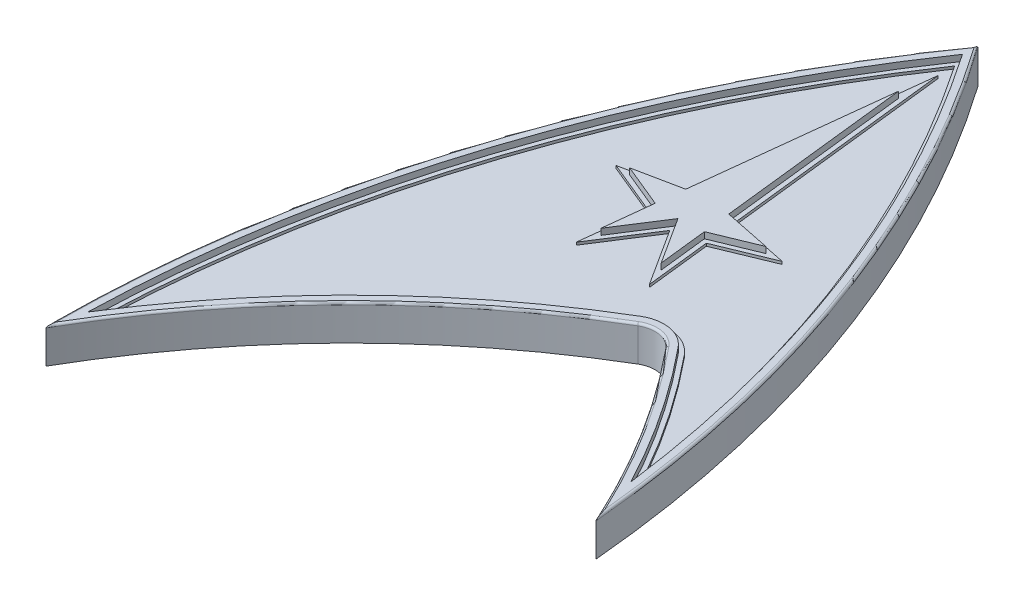
from build123d import *

# Parameters (mm, degrees)
BOSS_EXTRUDE4_START  = 2.3
BOSS_EXTRUDE4_DEPTH  = 0.7
BOSS_EXTRUDE5_DEPTH  = 3.3
BOSS_EXTRUDE6_DEPTH  = 3.3
BOSS_EXTRUDE7_DEPTH  = 4
BOSS_EXTRUDE8_DEPTH  = 4
BOSS_EXTRUDE11_DEPTH = 0.4
FILLET1_R            = 1
BOSS_EXTRUDE13_DEPTH = 0.4
FILLET2_R            = 0.25


with BuildPart() as part:
    # Sketch7 → Boss-Extrude4 (new body)
    with BuildSketch(Plane(origin=(0, 0, 0), x_dir=(1, 0, 0), z_dir=(0, 1, 0)).offset(BOSS_EXTRUDE4_START)):
        with BuildLine():
            ThreePointArc((25.3187138, 78.544271563), (7.774655726, 42.865584467), (1.048717339, 3.67981614))
            ThreePointArc((1.048717339, 3.67981614), (15.089584113, 21.033250642), (32.814888894, 34.601640347))
            ThreePointArc((32.814888894, 34.601640347), (35.548345535, 35.099201296), (37.946501588, 33.696275907))
            ThreePointArc((37.946501588, 33.696275907), (43.624222728, 26.008293603), (48.494904785, 17.785274356))
            ThreePointArc((48.494904785, 17.785274356), (40.509944663, 49.539169466), (25.3187138, 78.544271563))
        make_face()
        Polygon((25.3187138, 71.300701089), (22.880167391, 49.619221751), (17.607947401, 48.538636703), (22.53025342, 46.508084516), (21.9096513, 40.990218623), (25.3187138, 46.300701089), (28.7277763, 40.990218623), (28.107174179, 46.508084516), (33.029480199, 48.538636703), (27.757260208, 49.619221751), align=None, mode=Mode.SUBTRACT)
    extrude(amount=BOSS_EXTRUDE4_DEPTH)


with BuildPart() as body_2:
    # Sketch11 → Boss-Extrude5 (new body)
    with BuildSketch(Plane(origin=(0, 0, 0), x_dir=(1, 0, 0), z_dir=(0, 1, 0))):
        Polygon((25.3187138, 75.774305051), (22.423901789, 50.036100284), (15.905432755, 48.700086198), (21.991275042, 46.189551437), (21.173408654, 38.917779558), (25.3187138, 45.375147323), (29.464018945, 38.917779558), (28.646152557, 46.189551437), (34.731994844, 48.700086198), (28.21352581, 50.036100284), align=None)
    extrude(amount=BOSS_EXTRUDE5_DEPTH)

    # Sketch4 → Boss-Extrude8 (add)
    with BuildSketch(Plane(origin=(0, 0, 0), x_dir=(1, 0, 0), z_dir=(0, 1, 0))):
        Polygon((25.3187138, 71.300701089), (22.880167391, 49.619221751), (17.607947401, 48.538636703), (22.53025342, 46.508084516), (21.9096513, 40.990218623), (25.3187138, 46.300701089), (28.7277763, 40.990218623), (28.107174179, 46.508084516), (33.029480199, 48.538636703), (27.757260208, 49.619221751), align=None)
    extrude(amount=BOSS_EXTRUDE8_DEPTH)



with BuildPart() as body_3:
    # Sketch8 → Boss-Extrude6 (new body)
    with BuildSketch(Plane(origin=(0, 0, 0), x_dir=(1, 0, 0), z_dir=(0, 1, 0))):
        with BuildLine():
            ThreePointArc((25.3187138, 80.300701089), (6.479626895, 42.098811931), (0, 0))
            ThreePointArc((0, 0), (14.483479935, 19.022484189), (33.324507598, 33.741239989))
            ThreePointArc((33.324507598, 33.741239989), (35.374600079, 34.114410701), (37.173217119, 33.062216659))
            ThreePointArc((37.173217119, 33.062216659), (44.32763613, 23.058929343), (50.104685332, 12.201803985))
            ThreePointArc((50.104685332, 12.201803985), (42.194394509, 47.882820066), (25.3187138, 80.300701089))
        make_face()
        with BuildLine():
            ThreePointArc((25.3187138, 77.655988793), (8.417285199, 43.223132296), (1.60825988, 5.475058578))
            ThreePointArc((1.60825988, 5.475058578), (15.395050063, 22.022293224), (32.560079542, 35.031840527))
            ThreePointArc((32.560079542, 35.031840527), (35.635218263, 35.591596594), (38.333143822, 34.01330553))
            ThreePointArc((38.333143822, 34.01330553), (43.27239761, 27.425793547), (47.621637666, 20.434681115))
            ThreePointArc((47.621637666, 20.434681115), (39.681799875, 50.297117055), (25.3187138, 77.655988793))
        make_face(mode=Mode.SUBTRACT)
    extrude(amount=BOSS_EXTRUDE6_DEPTH)

    # Sketch5 → Boss-Extrude7 (add)
    with BuildSketch(Plane(origin=(0, 0, 0), x_dir=(1, 0, 0), z_dir=(0, 1, 0))):
        with BuildLine():
            ThreePointArc((33.324507598, 33.741239989), (14.483479935, 19.022484189), (0, 0))
            ThreePointArc((0, 0), (6.479626895, 42.098811931), (25.3187138, 80.300701089))
            ThreePointArc((25.3187138, 80.300701089), (42.194394509, 47.882820066), (50.104685332, 12.201803985))
            ThreePointArc((50.104685332, 12.201803985), (44.32763613, 23.058929343), (37.173217119, 33.062216659))
            ThreePointArc((37.173217119, 33.062216659), (35.374600079, 34.114410701), (33.324507598, 33.741239989))
        make_face()
        with BuildLine():
            ThreePointArc((48.494904785, 17.785274356), (43.624222728, 26.008293603), (37.946501588, 33.696275907))
            ThreePointArc((37.946501588, 33.696275907), (35.548345535, 35.099201296), (32.814888894, 34.601640347))
            ThreePointArc((32.814888894, 34.601640347), (15.089584113, 21.033250642), (1.048717339, 3.67981614))
            ThreePointArc((1.048717339, 3.67981614), (7.774655726, 42.865584467), (25.3187138, 78.544271563))
            ThreePointArc((25.3187138, 78.544271563), (40.509944663, 49.539169466), (48.494904785, 17.785274356))
        make_face(mode=Mode.SUBTRACT)
    extrude(amount=BOSS_EXTRUDE7_DEPTH)


with BuildPart() as body_2_1:
    add(body_2.part)

    add(body_3.part)  # Boss-Extrude11 merges body 3
    # Sketch14 → Boss-Extrude11 (add)
    with BuildSketch(Plane(origin=(0, 0, 0), x_dir=(1, 0, 0), z_dir=(0, 1, 0))):
        with BuildLine():
            ThreePointArc((33.324507598, 33.741239989), (14.483479935, 19.022484189), (0, 0))
            ThreePointArc((0, 0), (6.479626895, 42.098811931), (25.3187138, 80.300701089))
            ThreePointArc((25.3187138, 80.300701089), (42.194394509, 47.882820066), (50.104685332, 12.201803985))
            ThreePointArc((50.104685332, 12.201803985), (44.32763613, 23.058929343), (37.173217119, 33.062216659))
            ThreePointArc((37.173217119, 33.062216659), (35.374600079, 34.114410701), (33.324507598, 33.741239989))
        make_face()
        with BuildLine():
            Line((23.723630878, 70.539393135), (21.511370585, 50.869857351))
            Line((21.511370585, 50.869857351), (13.198167733, 49.16599774))
            ThreePointArc((13.198167733, 49.16599774), (17.991973603, 60.083620852), (23.723630878, 70.539393135))
        make_face(mode=Mode.SUBTRACT)
        with BuildLine():
            Line((13.054684669, 48.794332823), (20.913318286, 45.552485279))
            Line((20.913318286, 45.552485279), (19.700923362, 34.77290143))
            Line((19.700923362, 34.77290143), (25.3187138, 43.52403979))
            Line((25.3187138, 43.52403979), (29.919000612, 36.357922285))
            ThreePointArc((29.919000612, 36.357922285), (16.351293772, 26.297844628), (4.727035456, 14.043684112))
            ThreePointArc((4.727035456, 14.043684112), (7.744533302, 31.693714336), (13.054684669, 48.794332823))
        make_face(mode=Mode.SUBTRACT)
        with BuildLine():
            Line((30.704502872, 36.835660121), (29.724109313, 45.552485279))
            Line((29.724109313, 45.552485279), (37.58274293, 48.794332823))
            ThreePointArc((37.58274293, 48.794332823), (40.393915943, 40.733938341), (42.693859526, 32.513055637))
            ThreePointArc((42.693859526, 32.513055637), (41.495664758, 34.067994846), (40.266354995, 35.59845365))
            ThreePointArc((40.266354995, 35.59845365), (36.069581902, 38.053573082), (31.286032781, 37.182841422))
            ThreePointArc((31.286032781, 37.182841422), (30.994965848, 37.009756586), (30.704502872, 36.835660121))
        make_face(mode=Mode.SUBTRACT)
        with BuildLine():
            Line((37.439259866, 49.16599774), (29.126057014, 50.869857351))
            Line((29.126057014, 50.869857351), (26.913796721, 70.539393135))
            ThreePointArc((26.913796721, 70.539393135), (32.645453996, 60.083620852), (37.439259866, 49.16599774))
        make_face(mode=Mode.SUBTRACT)
    extrude(amount=BOSS_EXTRUDE11_DEPTH)

    # Fillet1
    fillet1_edges = [body_2_1.edges().sort_by_distance(p)[0] for p in [
        (29.919000612, 0.2, -36.357922285),
        (30.704502872, 0.2, -36.835660121),
        (37.439259866, 0.2, -49.16599774),
        (37.58274293, 0.2, -48.794332823),
        (13.054684669, 0.2, -48.794332823),
        (13.198167733, 0.2, -49.16599774),
    ]]
    fillet(fillet1_edges, radius=FILLET1_R)

    # Fillet2
    fillet2_edges = [body_2_1.edges().sort_by_distance(p)[0] for p in [
        (35.374600079, 4, -34.114410701),
        (44.32763613, 4, -23.058929343),
        (42.194394509, 4, -47.882820066),
        (6.479626895, 4, -42.098811931),
        (14.483479935, 4, -19.022484189),
    ]]
    fillet(fillet2_edges, radius=FILLET2_R)


with BuildPart() as body_3_2:
    # Sketch19 → Boss-Extrude13 (new body)
    with BuildSketch(Plane(origin=(0, 0.4, 0), x_dir=(1, 0, 0), z_dir=(0, 1, 0))):
        with BuildLine():
            Line((24.8466447, 76.050672339), (21.967636187, 50.452978818))
            Line((21.967636187, 50.452978818), (14.20291811, 48.861535693))
            Line((14.20291811, 48.861535693), (21.452296664, 45.871018358))
            Line((21.452296664, 45.871018358), (20.437166008, 36.845340494))
            Line((20.437166008, 36.845340494), (25.3187138, 44.449593557))
            Line((25.3187138, 44.449593557), (30.200261591, 36.845340494))
            Line((30.200261591, 36.845340494), (29.185130935, 45.871018358))
            Line((29.185130935, 45.871018358), (36.434509489, 48.861535693))
            Line((36.434509489, 48.861535693), (28.669791412, 50.452978818))
            Line((28.669791412, 50.452978818), (25.790782899, 76.050672339))
            ThreePointArc((25.790782899, 76.050672339), (39.0193522, 50.617007376), (46.707447601, 22.998905551))
            ThreePointArc((46.707447601, 22.998905551), (42.919872721, 28.810012622), (38.719786057, 34.330335154))
            ThreePointArc((38.719786057, 34.330335154), (35.722090991, 36.083991891), (32.30527019, 35.462040706))
            ThreePointArc((32.30527019, 35.462040706), (15.702286424, 23.001186092), (2.190151091, 7.241929563))
            ThreePointArc((2.190151091, 7.241929563), (8.92270814, 43.159512956), (24.8466447, 76.050672339))
        make_face()
    extrude(amount=BOSS_EXTRUDE13_DEPTH)


solid = Compound([part.part, body_2_1.part, body_3_2.part])
